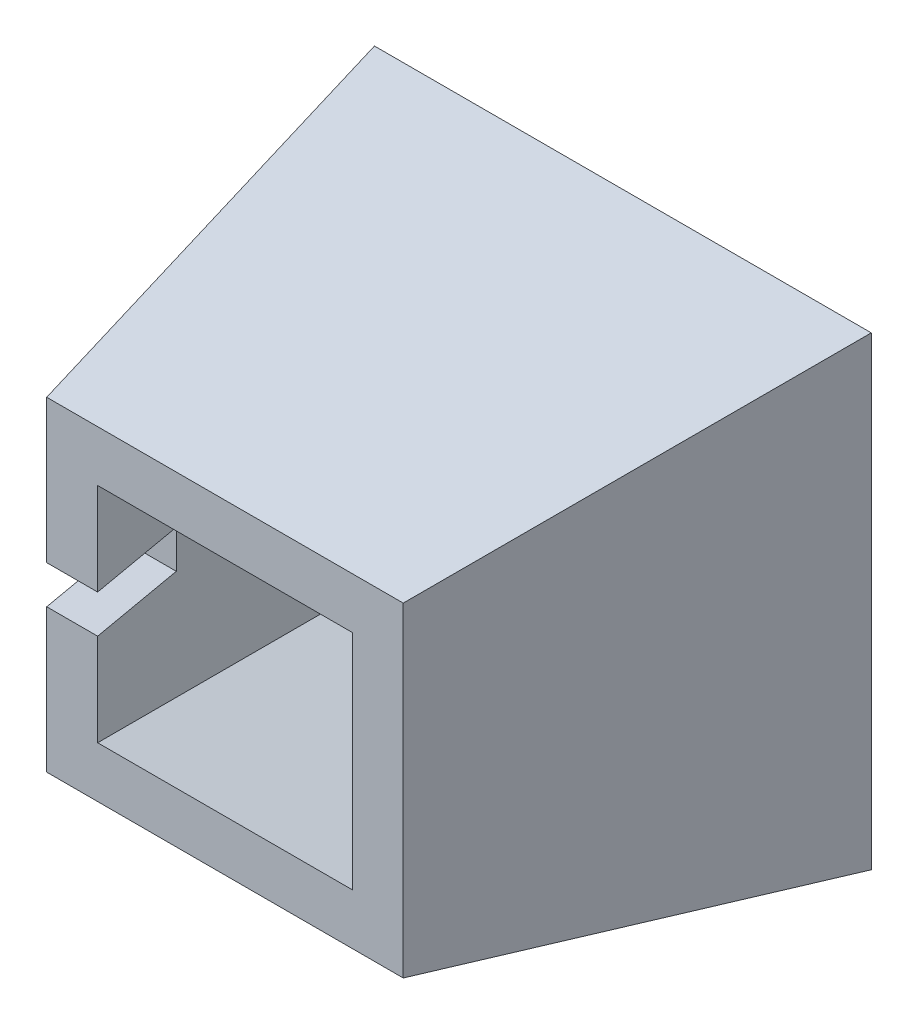
from build123d import *

# Parameters (mm, degrees)
SKETCH2_W                      = 112
SKETCH2_H                      = 102
BOSS_EXTRUDE1_DEPTH            = 125
BOSS_EXTRUDE1_TAPER            = -10
SKETCH3_W                      = 80
SKETCH3_H                      = 70
CUT_EXTRUDE1_DEPTH             = 125
CUT_EXTRUDE1_TAPER             = -10
CUT_EXTRUDE2_REACH             = 140.041
SKETCH5_W                      = 30
SKETCH5_H                      = 12
CUT_EXTRUDE2_DIRECTION_2_DEPTH = 10


with BuildPart() as part:
    # Sketch2 → Boss-Extrude1 (new body)
    with BuildSketch(Plane.XY):
        Rectangle(SKETCH2_W, SKETCH2_H)
    extrude(amount=-BOSS_EXTRUDE1_DEPTH, taper=BOSS_EXTRUDE1_TAPER)

    # Sketch3 → Cut-Extrude1 (cut)
    with BuildSketch(Plane(origin=(0, 0, 0), x_dir=(-1, 0, 0), z_dir=(0, 0, -1))):
        Rectangle(SKETCH3_W, SKETCH3_H)
    extrude(amount=CUT_EXTRUDE1_DEPTH, taper=CUT_EXTRUDE1_TAPER, mode=Mode.SUBTRACT)

    # Sketch5 → Cut-Extrude2 (cut, up to next)
    with BuildSketch(Plane(origin=(-60, 0, 0), x_dir=(0, 0, -1), z_dir=(1, 0, 0)), mode=Mode.PRIVATE) as cut_extrude2_sk1:
        with Locations((15, 0)):
            Rectangle(SKETCH5_W, SKETCH5_H)
    cut_extrude2_tool1 = extrude(cut_extrude2_sk1.sketch, amount=CUT_EXTRUDE2_REACH, mode=Mode.PRIVATE) & part.part
    add(cut_extrude2_tool1.solids().sort_by_distance((-60, 0, -15))[0], mode=Mode.SUBTRACT)

    # Sketch5 → Cut-Extrude2 direction 2 (cut)
    with BuildSketch(Plane(origin=(-60, 0, 0), x_dir=(0, 0, -1), z_dir=(1, 0, 0))):
        with Locations((15, 0)):
            Rectangle(SKETCH5_W, SKETCH5_H)
    extrude(amount=-CUT_EXTRUDE2_DIRECTION_2_DEPTH, mode=Mode.SUBTRACT)


solid = part.part
